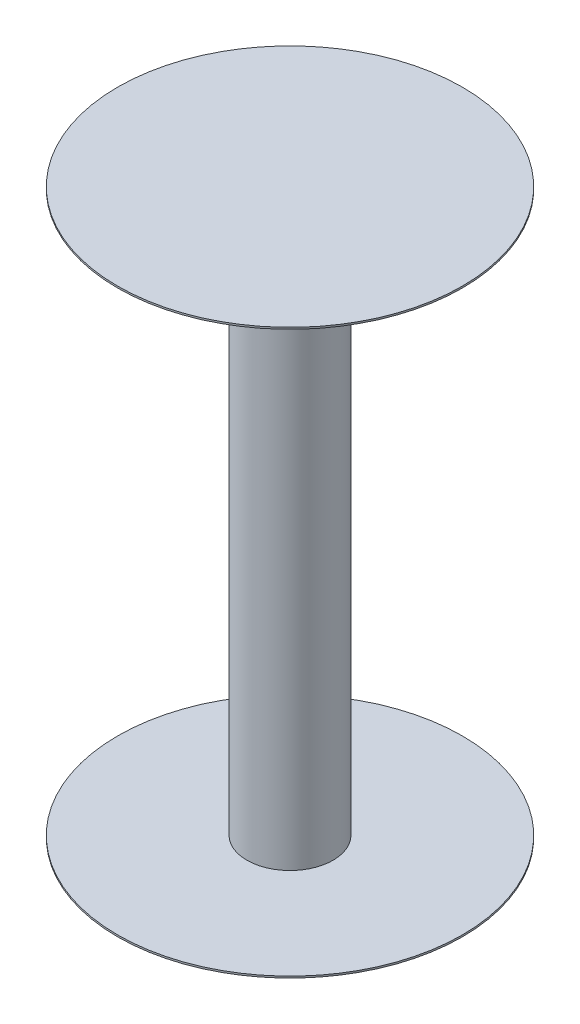
from build123d import *

# Parameters (mm, degrees)
SKETCH1_R           = 12.7
BOSS_EXTRUDE1_DEPTH = 82.55
SKETCH2_R           = 50.8
BOSS_EXTRUDE2_DEPTH = 0.508


with BuildPart() as part:
    # Sketch1 → Boss-Extrude1 (new body, symmetric)
    with BuildSketch(Plane(origin=(0, 0, 0), x_dir=(1, 0, 0), z_dir=(0, 1, 0))):
        Circle(SKETCH1_R)
    extrude(amount=BOSS_EXTRUDE1_DEPTH, both=True)

    # Sketch2 → Boss-Extrude2 (add)
    with BuildSketch(Plane(origin=(0, 82.55, 0), x_dir=(1, 0, 0), z_dir=(0, 1, 0))):
        Circle(SKETCH2_R)
    boss_extrude2 = extrude(amount=BOSS_EXTRUDE2_DEPTH)

    # Mirror1: Boss-Extrude2 across plane
    add(boss_extrude2.mirror(Plane.ZX))


solid = part.part
